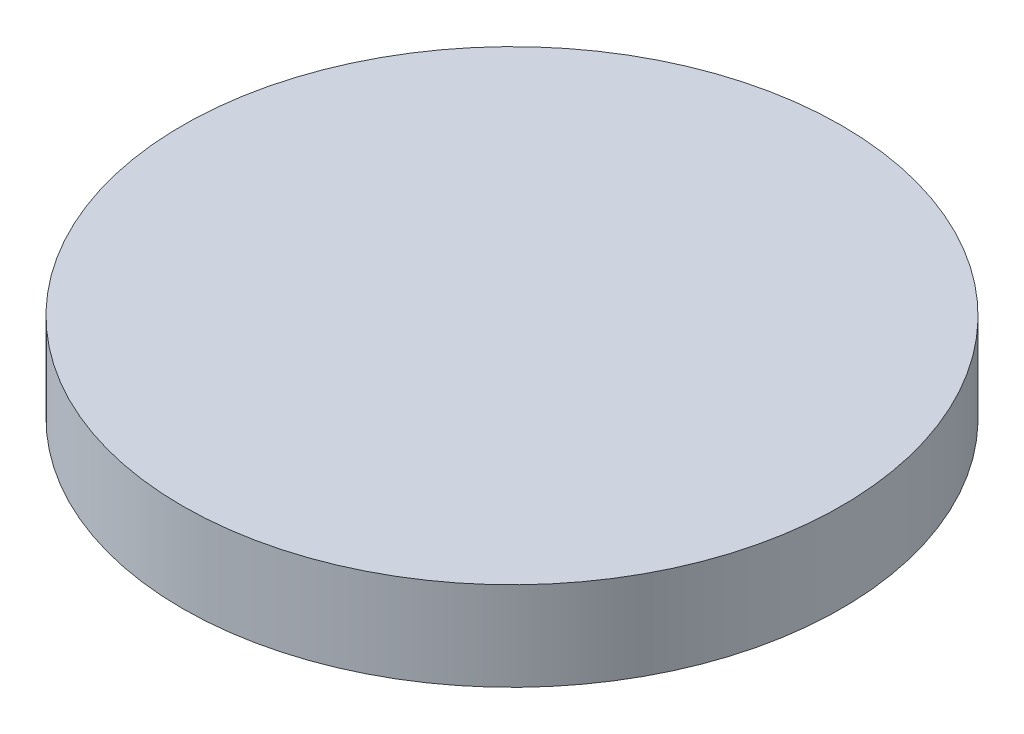
from build123d import *

# Parameters (mm, degrees)
SKETCH1_R           = 12.25
BOSS_EXTRUDE1_DEPTH = 3.302


with BuildPart() as part:
    # Sketch1 → Boss-Extrude1 (new body)
    with BuildSketch(Plane(origin=(0, 0, 0), x_dir=(1, 0, 0), z_dir=(0, 1, 0))):
        Circle(SKETCH1_R)
    extrude(amount=BOSS_EXTRUDE1_DEPTH)


solid = part.part
